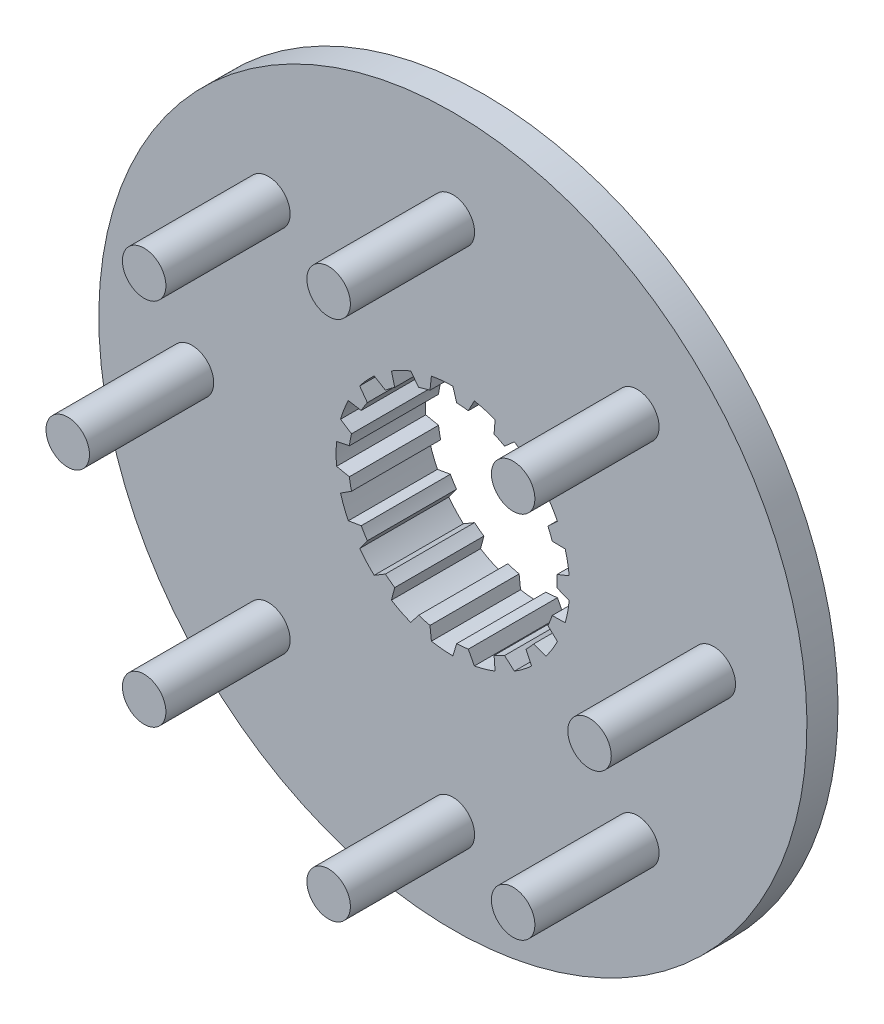
from build123d import *

# Parameters (mm, degrees)
CUT_EXTRUDE1_DEPTH  = 15.35
CIRPATTERN1_COUNT   = 17
SKETCH3_R           = 3.5
BOSS_EXTRUDE1_DEPTH = 20


with BuildPart() as part:
    # Sketch1 → Revolve1 (revolve)
    with BuildSketch(Plane(origin=(0, 0, 0), x_dir=(0, 0, -1), z_dir=(1, 0, 0))):
        Polygon((0, 0), (0, 57), (5, 57), (5, 25.000000038), (14.35, 25.000000038), (14.35, 0), align=None)
    revolve(axis=Axis((0, 0, -14.35), (0, 0, 1)))

    # Sketch2 → Cut-Extrude1 (cut, through all)
    with BuildSketch(Plane(origin=(0, 0, -14.35), x_dir=(-1, 0, 0), z_dir=(0, 0, -1))):
        with BuildLine():
            Line((0, 0), (0, 18.8))
            ThreePointArc((0, 18.8), (1.734645158, 18.719802514), (3.454490935, 18.479894274))
            Line((3.454490935, 18.479894274), (3.685673166, 16.390723392))
            ThreePointArc((3.685673166, 16.390723392), (4.597538233, 16.158670805), (5.494981484, 15.875930791))
            Line((5.494981484, 15.875930791), (6.791343324, 17.530477913))
            Line((6.791343324, 17.530477913), (0, 0))
        make_face()
    cut_extrude1 = extrude(amount=-CUT_EXTRUDE1_DEPTH, mode=Mode.SUBTRACT)

    # CirPattern1: Cut-Extrude1 ×17 about axis
    cirpattern1_axis = Axis((0, 0, 0), (0, 0, 1))
    for i in range(1, CIRPATTERN1_COUNT):
        add(cut_extrude1.rotate(cirpattern1_axis, i * 360 / CIRPATTERN1_COUNT), mode=Mode.SUBTRACT)

    # Sketch3 → Boss-Extrude1 (add)
    with BuildSketch(Plane.XY):
        with Locations((0, 42)):
            Circle(SKETCH3_R)
        with Locations((29.69848481, 29.69848481)):
            Circle(SKETCH3_R)
        with Locations((42, 0)):
            Circle(SKETCH3_R)
        with Locations((29.69848481, -29.69848481)):
            Circle(SKETCH3_R)
        with Locations((0, -42)):
            Circle(SKETCH3_R)
        with Locations((-29.69848481, -29.69848481)):
            Circle(SKETCH3_R)
        with Locations((-42, 0)):
            Circle(SKETCH3_R)
        with Locations((-29.69848481, 29.69848481)):
            Circle(SKETCH3_R)
    extrude(amount=BOSS_EXTRUDE1_DEPTH)


solid = part.part
